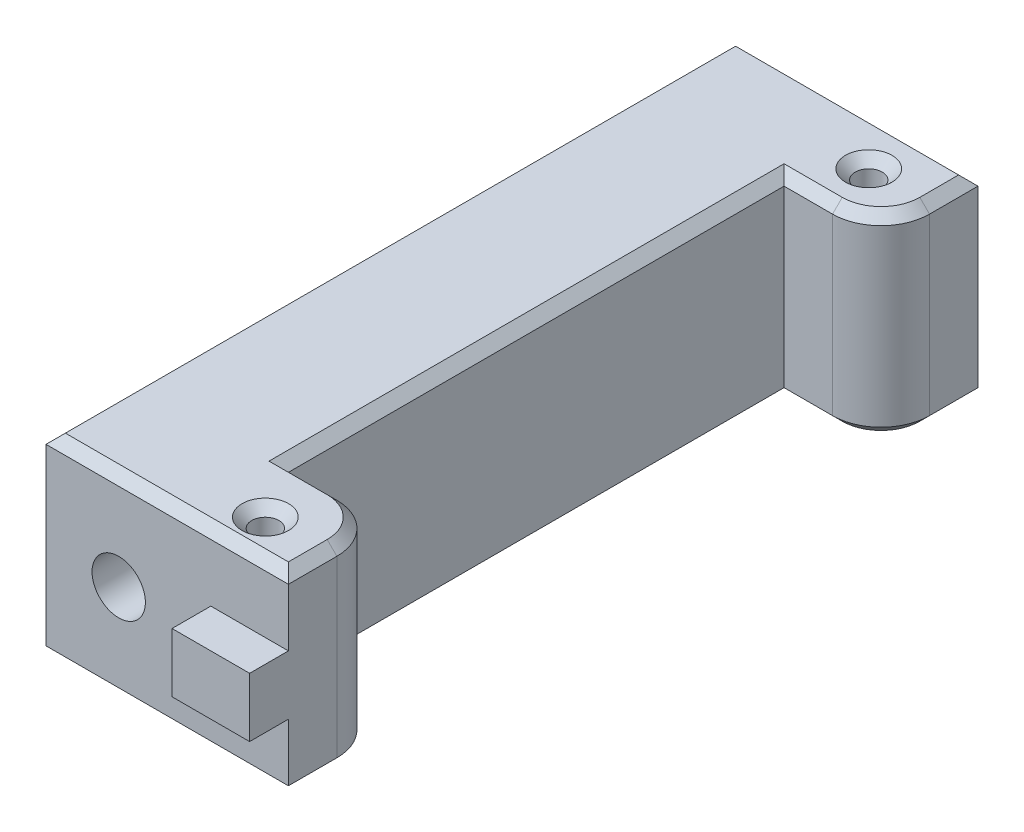
from build123d import *

# Parameters (mm, degrees)
BOSS_EXTRUDE1_DEPTH            = 20
CBORE_FOR_M5_SHCS1_D           = 5.5
CBORE_FOR_M5_SHCS1_CBORE_D     = 10
CBORE_FOR_M5_SHCS1_CBORE_DEPTH = 65
SKETCH5_W                      = 8
SKETCH5_H                      = 6.1
BOSS_EXTRUDE2_DEPTH            = 4
SKETCH6_R                      = 1.4
CUT_EXTRUDE1_DEPTH             = 21
FILLET1_R                      = 5
CHAMFER2_SIZE                  = 1


with BuildPart() as part:
    # Sketch1 → Boss-Extrude1 (new body)
    with BuildSketch(Plane(origin=(0, 0, 0), x_dir=(1, 0, 0), z_dir=(0, 1, 0))):
        Polygon((0, 0), (0, 71.12), (25, 71.12), (25, 61.12), (15, 61.12), (15, 10), (25, 10), (25, 0), align=None)
    extrude(amount=BOSS_EXTRUDE1_DEPTH)

    # CBORE for M5 SHCS1 (through all)
    with Locations(Plane(origin=(0, 0, -71.12), x_dir=(-1, 0, 0), z_dir=(0, 0, -1))):
        with Locations((-7.5, 10)):
            CounterBoreHole(CBORE_FOR_M5_SHCS1_D / 2, CBORE_FOR_M5_SHCS1_CBORE_D / 2, CBORE_FOR_M5_SHCS1_CBORE_DEPTH)

    # Sketch5 → Boss-Extrude2 (add)
    with BuildSketch(Plane.XY):
        with Locations((21, 10)):
            Rectangle(SKETCH5_W, SKETCH5_H)
    extrude(amount=BOSS_EXTRUDE2_DEPTH)

    # Sketch6 → Cut-Extrude1 (cut, through all)
    with BuildSketch(Plane.XZ):
        with Locations((18.81, -3.81)):
            Circle(SKETCH6_R)
        with Locations((18.81, -66.04)):
            Circle(SKETCH6_R)
    extrude(amount=-CUT_EXTRUDE1_DEPTH, mode=Mode.SUBTRACT)

    # Fillet1
    fillet1_edges = [part.edges().sort_by_distance(p)[0] for p in [
        (25, 10, -61.12),
        (25, 10, -10),
    ]]
    fillet(fillet1_edges, radius=FILLET1_R)

    # Chamfer2
    chamfer2_edges = [part.edges().sort_by_distance(p)[0] for p in [
        (15, 0, -35.56),
        (25, 0, -2.5),
        (12.5, 0, 0),
        (15, 20, -35.56),
        (17.5, 20, -61.12),
        (12.5, 20, -71.12),
        (0, 20, -35.56),
        (17.41, 20, -3.81),
        (17.41, 0, -3.81),
        (17.41, 20, -66.04),
        (17.41, 0, -66.04),
        (12.5, 20, 0),
        (17.5, 0, -10),
        (17.5, 20, -10),
        (25, 0, -68.62),
        (23.535533906, 0, -62.584466094),
        (23.535533906, 0, -8.535533906),
        (25, 20, -68.62),
        (23.535533906, 20, -62.584466094),
        (23.535533906, 20, -8.535533906),
        (0, 0, -35.56),
        (25, 20, -2.5),
        (12.5, 0, -71.12),
        (17.5, 0, -61.12),
    ]]
    chamfer(chamfer2_edges, length=CHAMFER2_SIZE)


solid = part.part
